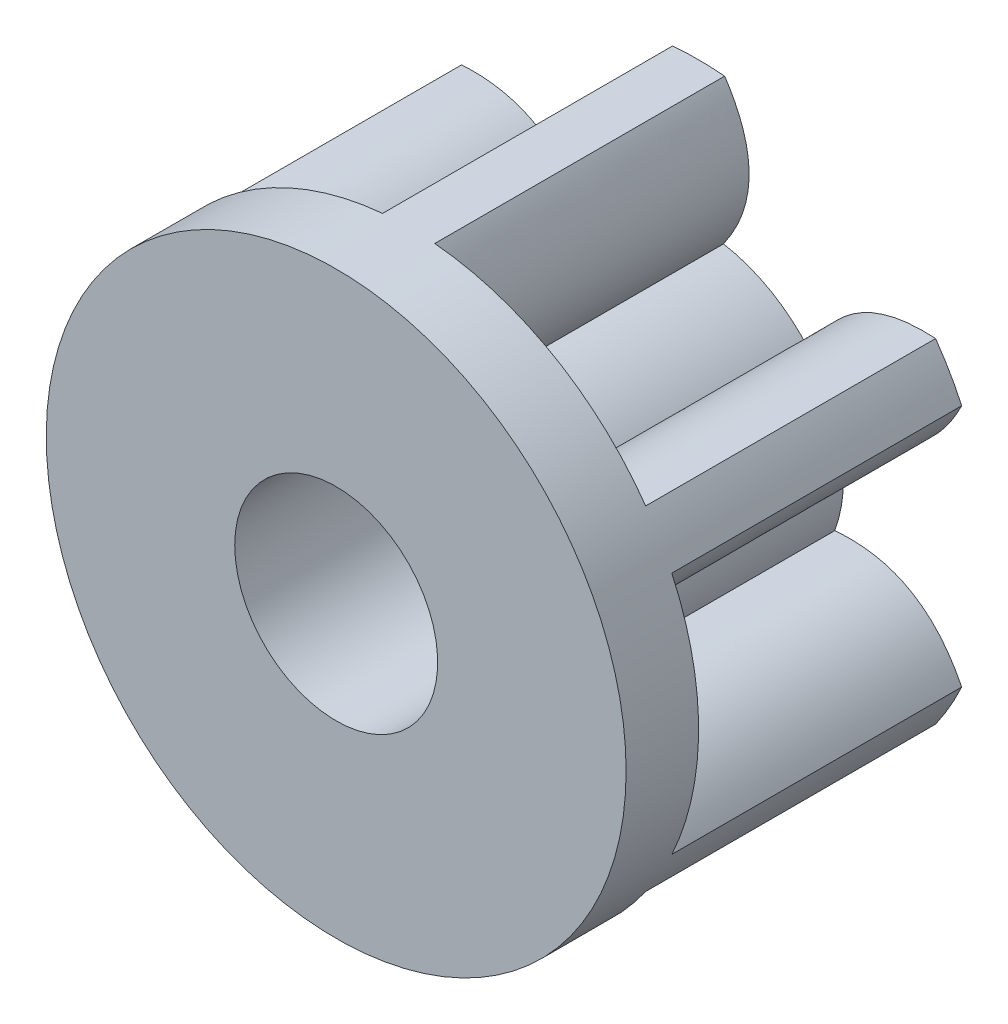
from build123d import *

# Parameters (mm, degrees)
EXTRUDE_1_DEPTH     = 2
SKETCH_2_R          = 2
EXTRUDE_2_DEPTH     = 0.5
SKETCH_3_R          = 0.7
CUT_EXTRUDE_1_DEPTH = 3.5


with BuildPart() as part:
    # 草图1 → 凸台-拉伸1 (new body)
    with BuildSketch(Plane.XY):
        with BuildLine():
            ThreePointArc((-0.171402668, 0.985201058), (-0.5, 0.866025404), (-0.767507811, 0.641039594))
            add(Edge.make_bspline(
                [(-1.635127173, 1.15167666), (-1.021084682, 1.190983914), (-0.767507811, 0.641039594)],
                knots=[0, 0, 0, 1, 1, 1], degree=2))
            ThreePointArc((-1.635127173, 1.15167666), (-1.732096577, 0.999920721), (-1.815021739, 0.840057193))
            add(Edge.make_bspline(
                [(-1.815021739, 0.840057193), (-1.541873553, 0.288839145), (-0.938910478, 0.344161465)],
                knots=[0, 0, 0, 1, 1, 1], degree=2))
            ThreePointArc((-0.938910478, 0.344161465), (-1, 0), (-0.938910478, -0.344161465))
            add(Edge.make_bspline(
                [(-1.814944831, -0.84022334), (-1.541964666, -0.288793317), (-0.938910478, -0.344161465)],
                knots=[0, 0, 0, 1, 1, 1], degree=2))
            ThreePointArc((-1.814944831, -0.84022334), (-1.732005035, -1.000079277), (-1.635021739, -1.151826338))
            add(Edge.make_bspline(
                [(-1.635021739, -1.151826338), (-1.021078814, -1.190882094), (-0.767507811, -0.641039594)],
                knots=[0, 0, 0, 1, 1, 1], degree=2))
            ThreePointArc((-0.767507811, -0.641039594), (-0.5, -0.866025404), (-0.171402668, -0.985201058))
            add(Edge.make_bspline(
                [(-0.179817658, -1.9919), (-0.520879984, -1.479777231), (-0.171402668, -0.985201058)],
                knots=[0, 0, 0, 1, 1, 1], degree=2))
            ThreePointArc((-0.179817658, -1.9919), (9.1542e-05, -1.999999998), (0.18, -1.991883531))
            add(Edge.make_bspline(
                [(0.18, -1.991883531), (0.520794739, -1.479721239), (0.171402668, -0.985201058)],
                knots=[0, 0, 0, 1, 1, 1], degree=2))
            ThreePointArc((0.171402668, -0.985201058), (0.5, -0.866025404), (0.767507811, -0.641039594))
            add(Edge.make_bspline(
                [(1.635127173, -1.15167666), (1.021084682, -1.190983914), (0.767507811, -0.641039594)],
                knots=[0, 0, 0, 1, 1, 1], degree=2))
            ThreePointArc((1.635127173, -1.15167666), (1.732096577, -0.999920721), (1.815021739, -0.840057193))
            add(Edge.make_bspline(
                [(1.815021739, -0.840057193), (1.541873553, -0.288839145), (0.938910478, -0.344161465)],
                knots=[0, 0, 0, 1, 1, 1], degree=2))
            ThreePointArc((0.938910478, -0.344161465), (1, 0), (0.938910478, 0.344161465))
            add(Edge.make_bspline(
                [(1.814944831, 0.84022334), (1.541964666, 0.288793317), (0.938910478, 0.344161465)],
                knots=[0, 0, 0, 1, 1, 1], degree=2))
            ThreePointArc((1.814944831, 0.84022334), (1.732005035, 1.000079277), (1.635021739, 1.151826338))
            add(Edge.make_bspline(
                [(1.635021739, 1.151826338), (1.021078814, 1.190882094), (0.767507811, 0.641039594)],
                knots=[0, 0, 0, 1, 1, 1], degree=2))
            ThreePointArc((0.767507811, 0.641039594), (0.5, 0.866025404), (0.171402668, 0.985201058))
            add(Edge.make_bspline(
                [(0.179817658, 1.9919), (0.520879984, 1.479777231), (0.171402668, 0.985201058)],
                knots=[0, 0, 0, 1, 1, 1], degree=2))
            ThreePointArc((0.179817658, 1.9919), (-9.1542e-05, 1.999999998), (-0.18, 1.991883531))
            add(Edge.make_bspline(
                [(-0.18, 1.991883531), (-0.520794739, 1.479721239), (-0.171402668, 0.985201058)],
                knots=[0, 0, 0, 1, 1, 1], degree=2))
        make_face()
    extrude(amount=EXTRUDE_1_DEPTH)

    # 草图2 → 凸台-拉伸2 (add)
    with BuildSketch(Plane.XY.offset(2)):
        Circle(SKETCH_2_R)
    extrude(amount=EXTRUDE_2_DEPTH)

    # 草图3 → 切除-拉伸1 (cut, through all)
    with BuildSketch(Plane(origin=(0, 0, 0), x_dir=(-1, 0, 0), z_dir=(0, 0, -1))):
        Circle(SKETCH_3_R)
    extrude(amount=-CUT_EXTRUDE_1_DEPTH, mode=Mode.SUBTRACT)


solid = part.part
